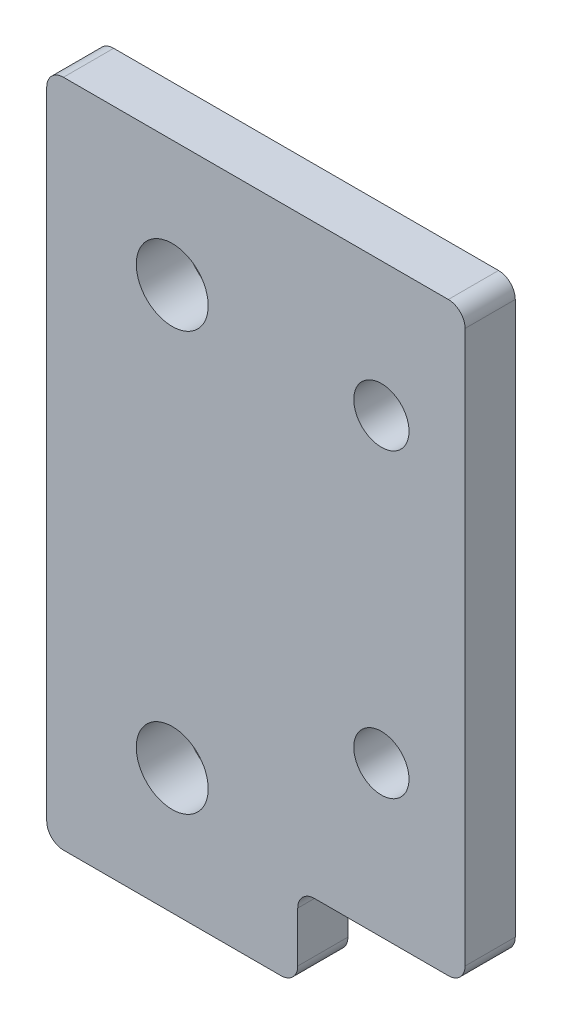
from build123d import *

# Parameters (mm, degrees)
SKETCH_1_R      = 2.15
SKETCH_1_R_2    = 1.65
EXTRUDE_1_DEPTH = 3
FILLET_1_R      = 1


with BuildPart() as part:
    # 草图1 → 凸台-拉伸1 (new body)
    with BuildSketch(Plane.XY):
        Polygon((7.5, 32.5), (17.5, 32.5), (17.5, -2.5), (7.5, -2.5), (7.5, -7.5), (-7.5, -7.5), (-7.5, 32.5), align=None)
        Circle(SKETCH_1_R, mode=Mode.SUBTRACT)
        with Locations((0, 25)):
            Circle(SKETCH_1_R, mode=Mode.SUBTRACT)
        with Locations((12.5, 24.5)):
            Circle(SKETCH_1_R_2, mode=Mode.SUBTRACT)
        with Locations((12.5, 6.5)):
            Circle(SKETCH_1_R_2, mode=Mode.SUBTRACT)
    extrude(amount=EXTRUDE_1_DEPTH)

    # 圆角1
    fillet_1_edges = [part.edges().sort_by_distance(p)[0] for p in [
        (7.5, -7.5, 1.5),
        (-7.5, -7.5, 1.5),
        (-7.5, 32.5, 1.5),
        (17.5, 32.5, 1.5),
        (17.5, -2.5, 1.5),
        (7.5, -2.5, 1.5),
    ]]
    fillet(fillet_1_edges, radius=FILLET_1_R)


solid = part.part
